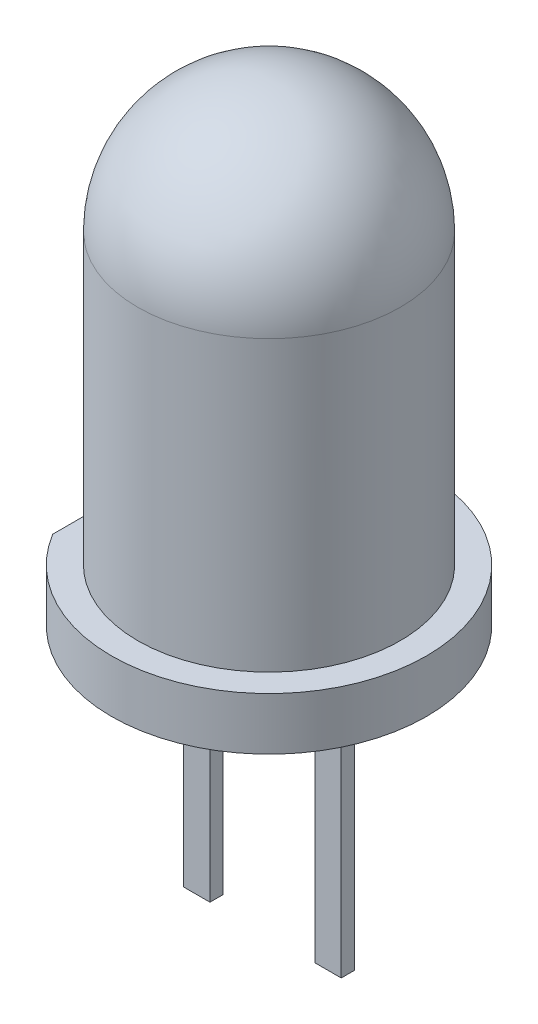
from build123d import *

# Parameters (mm, degrees)
SKETCH4_W       = 0.5
SKETCH4_H       = 3.5
EXTRUDE4_DEPTH  = 2
SKETCH2_W       = 0.5
SKETCH2_H       = 0.25
EXTRUDE_1_DEPTH = 5


with BuildPart() as part:
    # Sketch1 → Revolve1 (revolve)
    with BuildSketch(Plane.XY):
        with BuildLine():
            Line((0, 2.5), (0, -5.5))
            Line((0, -5.5), (0, -6.5))
            Line((0, -6.5), (3, -6.5))
            Line((3, -6.5), (3, -5.5))
            Line((3, -5.5), (2.5, -5.5))
            Line((2.5, -5.5), (2.5, 0))
            ThreePointArc((2.5, 0), (1.767766953, 1.767766953), (0, 2.5))
        make_face()
    revolve(axis=Axis((0, 40.48125, 0), (0, -1, 0)))

    # Sketch4 → Extrude4 (cut)
    with BuildSketch(Plane.XZ.offset(6.5)):
        with Locations((-2.817517664, 0)):
            Rectangle(SKETCH4_W, SKETCH4_H)
    extrude(amount=-EXTRUDE4_DEPTH, mode=Mode.SUBTRACT)

    # Sketch2 → 凸台-拉伸1 (add)
    with BuildSketch(Plane.XZ.offset(6.5)):
        with Locations((1.25, 0)):
            Rectangle(SKETCH2_W, SKETCH2_H)
        with Locations((-1.25, 0)):
            Rectangle(SKETCH2_W, SKETCH2_H)
    extrude(amount=EXTRUDE_1_DEPTH)


solid = part.part
